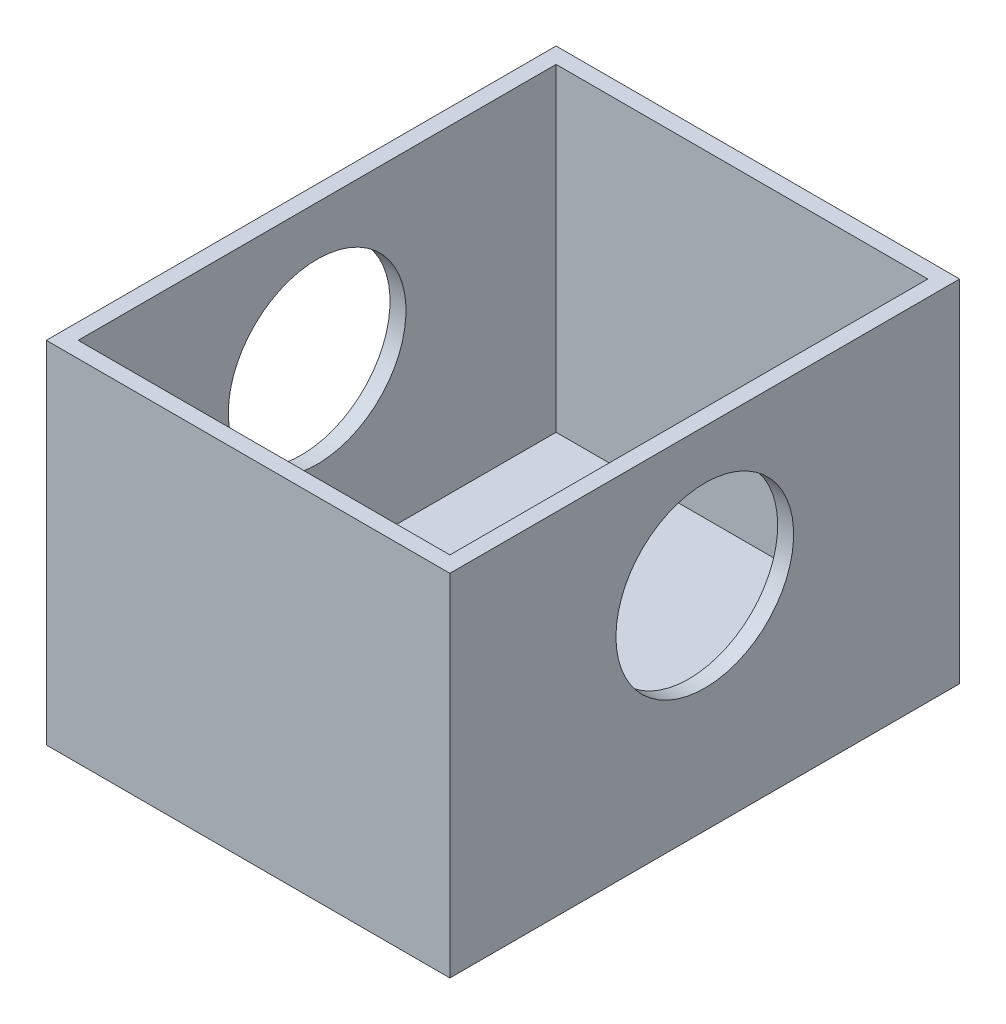
from build123d import *

# Parameters (mm, degrees)
SKETCH1_W           = 9.652
SKETCH1_H           = 12.192
BOSS_EXTRUDE1_DEPTH = 8.382
SKETCH4_W           = 8.89
SKETCH4_H           = 11.43
CUT_EXTRUDE1_DEPTH  = 7.62
SKETCH6_R           = 2.12471
CUT_EXTRUDE2_DEPTH  = 10.652


with BuildPart() as part:
    # Sketch1 → Boss-Extrude1 (new body)
    with BuildSketch(Plane(origin=(0, 0, 0), x_dir=(1, 0, 0), z_dir=(0, 1, 0))):
        with Locations((-3.14180083, 1.47973444)):
            Rectangle(SKETCH1_W, SKETCH1_H)
    extrude(amount=BOSS_EXTRUDE1_DEPTH)

    # Sketch4 → Cut-Extrude1 (cut)
    with BuildSketch(Plane(origin=(0, 8.382, 0), x_dir=(1, 0, 0), z_dir=(0, 1, 0))):
        with Locations((-3.14180083, 1.47973444)):
            Rectangle(SKETCH4_W, SKETCH4_H)
    extrude(amount=-CUT_EXTRUDE1_DEPTH, mode=Mode.SUBTRACT)

    # Sketch6 → Cut-Extrude2 (cut, through all)
    with BuildSketch(Plane.ZY.offset(7.96780083)):
        with Locations((-1.47973444, 5.08)):
            Circle(SKETCH6_R)
    extrude(amount=-CUT_EXTRUDE2_DEPTH, mode=Mode.SUBTRACT)


solid = part.part
